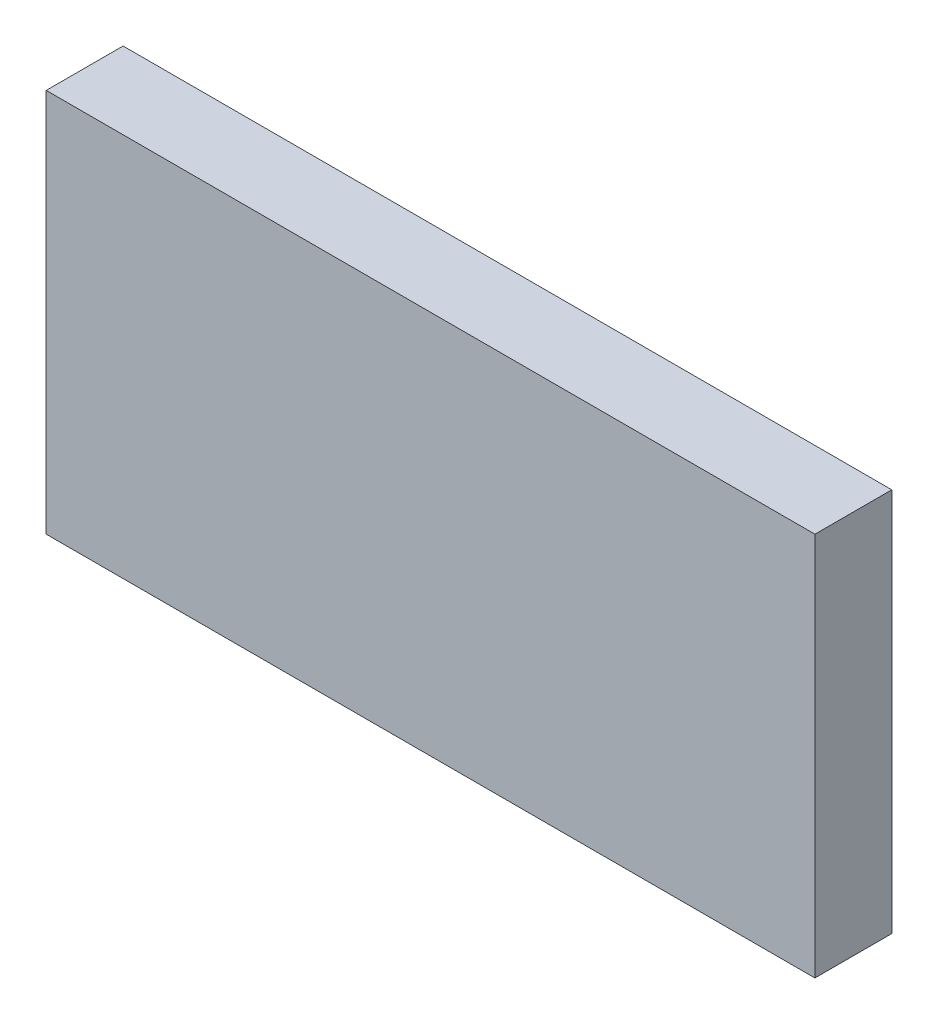
from build123d import *

# Parameters (mm, degrees)
ESQUISSE1_W        = 100
ESQUISSE1_H        = 50
BOSS_EXTRU_1_DEPTH = 5


with BuildPart() as part:
    # Esquisse1 → Boss.-Extru.1 (new body, symmetric)
    with BuildSketch(Plane.XY):
        Rectangle(ESQUISSE1_W, ESQUISSE1_H)
    extrude(amount=BOSS_EXTRU_1_DEPTH, both=True)


solid = part.part
